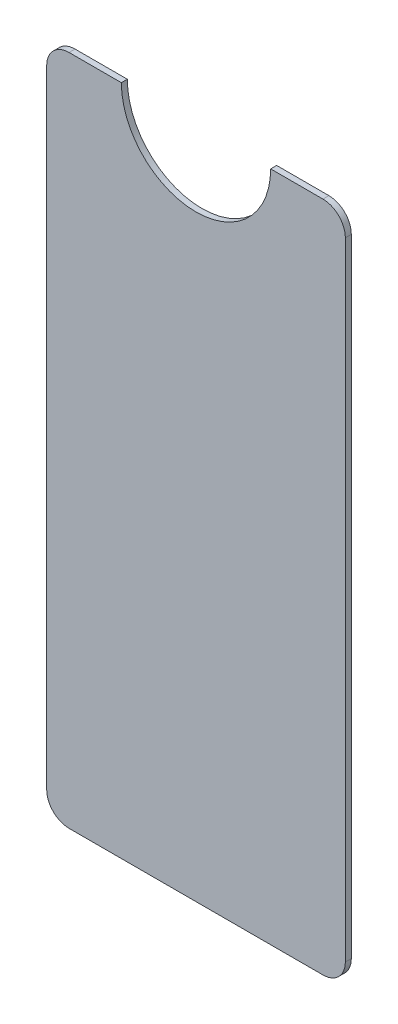
from build123d import *

# Parameters (mm, degrees)
BOSS_EXTRUDE1_DEPTH = 0.8


with BuildPart() as part:
    # Sketch1 → Boss-Extrude1 (new body)
    with BuildSketch(Plane.XY):
        with BuildLine():
            Line((30, 90), (37, 90))
            ThreePointArc((37, 90), (39.121320344, 89.121320344), (40, 87))
            Line((40, 87), (40, 3))
            ThreePointArc((40, 3), (39.121320344, 0.878679656), (37, 0))
            Line((37, 0), (3, 0))
            ThreePointArc((3, 0), (0.878679656, 0.878679656), (0, 3))
            Line((0, 3), (0, 87))
            ThreePointArc((0, 87), (0.878679656, 89.121320344), (3, 90))
            Line((3, 90), (10, 90))
            ThreePointArc((10, 90), (20, 80), (30, 90))
        make_face()
    extrude(amount=BOSS_EXTRUDE1_DEPTH)


solid = part.part
